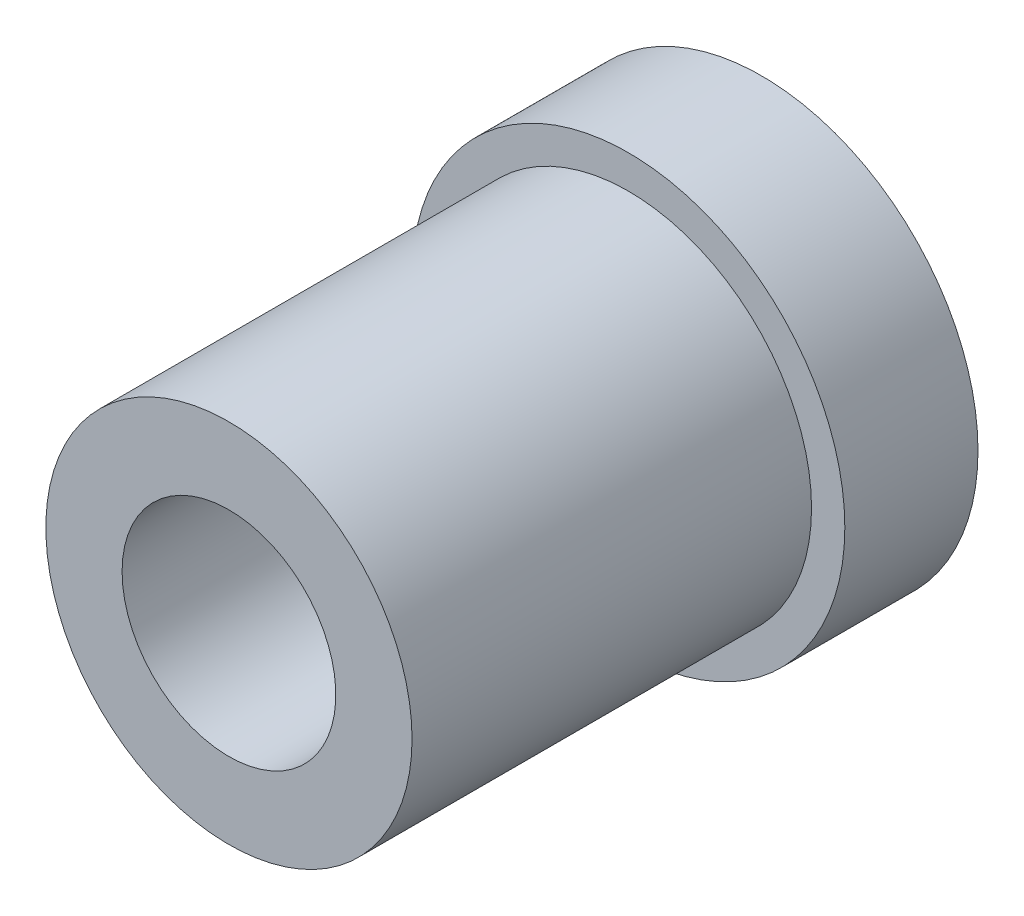
from build123d import *

# Parameters (mm, degrees)
ESQUISSE1_R             = 32.5
BOSS_EXTRU_1_DEPTH      = 20
ESQUISSE2_R             = 27.5
BOSS_EXTRU_2_DEPTH      = 80
ESQUISSE3_R             = 16.05
ENL_V_MAT_EXTRU_1_DEPTH = 81


with BuildPart() as part:
    # Esquisse1 → Boss.-Extru.1 (new body)
    with BuildSketch(Plane.XY):
        Circle(ESQUISSE1_R)
    extrude(amount=BOSS_EXTRU_1_DEPTH)

    # Esquisse2 → Boss.-Extru.2 (add)
    with BuildSketch(Plane.XY):
        Circle(ESQUISSE2_R)
    extrude(amount=BOSS_EXTRU_2_DEPTH)

    # Esquisse3 → Enlèv. mat.-Extru.1 (cut, through all)
    with BuildSketch(Plane(origin=(0, 0, 0), x_dir=(-1, 0, 0), z_dir=(0, 0, -1))):
        Circle(ESQUISSE3_R)
    extrude(amount=-ENL_V_MAT_EXTRU_1_DEPTH, mode=Mode.SUBTRACT)


solid = part.part
